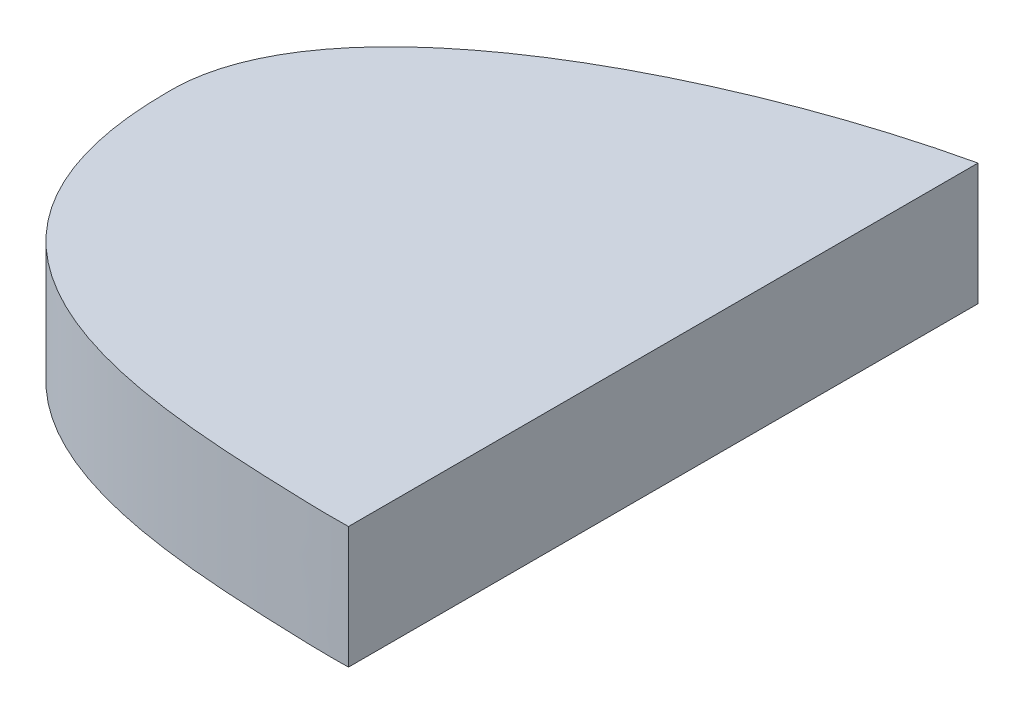
from build123d import *

# Parameters (mm, degrees)
BOSS_EXTRUDE1_DEPTH = 10
SKETCH4_W           = 100.618429476
SKETCH4_H           = 73.47084465
CUT_EXTRUDE1_DEPTH  = 11.0000001


with BuildPart() as part:
    # Sketch2 → Boss-Extrude1 (new body)
    with BuildSketch(Plane(origin=(0, 0, 0), x_dir=(1, 0, 0), z_dir=(0, 1, 0))):
        with BuildLine():
            add(Edge.make_bspline(
                [(-109.1, -5.1), (-109.424609826, 10.441471911), (-73.787625733, 25.22270358), (-43.020276746, 23.937309848), (-34.219540496, 17.85083091), (-19.745412821, 17.556799812), (-9.831464388, 20.08956268), (7.173597662, 19.935183257), (19.6, 14.289300505), (19.6, 0)],
                knots=[0, 0, 0, 0, 0.230584101, 0.286176341, 0.525950611, 0.574149071, 0.719962477, 0.764370237, 1, 1, 1, 1], degree=3))
            add(Edge.make_bspline(
                [(19.6, 0), (19.6, -12.798208112), (9.628339195, -19.558649887), (-8.537408911, -19.135204318), (-19.796385689, -17.357223298), (-41.21861702, -17.372886462), (-58.113965099, -28.979482333), (-85.155395015, -28.327654779), (-109.1, -26.64326042), (-109.1, -5.1)],
                knots=[0, 0, 0, 0, 0.174620331, 0.213184502, 0.3664798, 0.418282358, 0.679407529, 0.740843358, 1, 1, 1, 1], degree=3))
        make_face()
    extrude(amount=BOSS_EXTRUDE1_DEPTH)

    # Sketch4 → Cut-Extrude1 (cut, through all)
    with BuildSketch(Plane(origin=(0, 10, 0), x_dir=(1, 0, 0), z_dir=(0, 1, 0))):
        with Locations((-20.483666123, -0.100088959)):
            Rectangle(SKETCH4_W, SKETCH4_H)
    extrude(amount=-CUT_EXTRUDE1_DEPTH, mode=Mode.SUBTRACT)


solid = part.part
